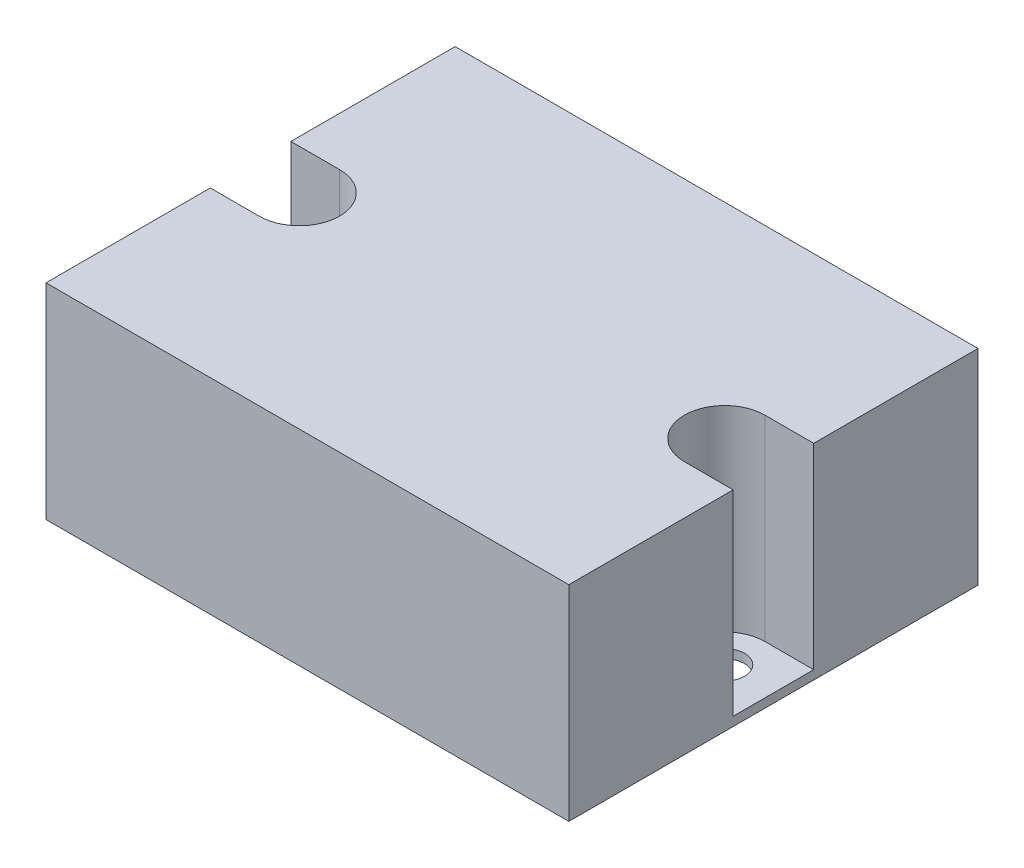
from build123d import *

# Parameters (mm, degrees)
SKETCH1_R           = 2.225
BASEPLATE_DEPTH     = 1
BOSS_EXTRUDE4_DEPTH = 21.9


with BuildPart() as part:
    # Sketch1 → BasePlate (new body)
    with BuildSketch(Plane(origin=(0, 0, 0), x_dir=(1, 0, 0), z_dir=(0, 1, 0))):
        with BuildLine():
            Line((5.45, 25.1), (0, 25.1))
            Line((0, 25.1), (0, 45.7))
            Line((0, 45.7), (58.4, 45.7))
            Line((58.4, 45.7), (58.4, 0))
            Line((58.4, 0), (0, 0))
            Line((0, 0), (0, 20.6))
            Line((0, 20.6), (5.45, 20.6))
            ThreePointArc((5.45, 20.6), (7.7, 22.85), (5.45, 25.1))
        make_face()
        with Locations((52.95, 22.85)):
            Circle(SKETCH1_R, mode=Mode.SUBTRACT)
    extrude(amount=BASEPLATE_DEPTH)

    # Sketch2 → Boss-Extrude4 (add)
    with BuildSketch(Plane(origin=(0, 1, 0), x_dir=(1, 0, 0), z_dir=(0, 1, 0))):
        with BuildLine():
            Line((52.95, 27.35), (58.4, 27.35))
            Line((58.4, 27.35), (58.4, 45.7))
            Line((58.4, 45.7), (0, 45.7))
            Line((0, 45.7), (0, 27.35))
            Line((0, 27.35), (5.45, 27.35))
            ThreePointArc((5.45, 27.35), (9.95, 22.85), (5.45, 18.35))
            Line((5.45, 18.35), (0, 18.35))
            Line((0, 18.35), (0, 0))
            Line((0, 0), (58.4, 0))
            Line((58.4, 0), (58.4, 18.35))
            Line((58.4, 18.35), (52.95, 18.35))
            ThreePointArc((52.95, 18.35), (48.45, 22.85), (52.95, 27.35))
        make_face()
    extrude(amount=BOSS_EXTRUDE4_DEPTH)


solid = part.part
